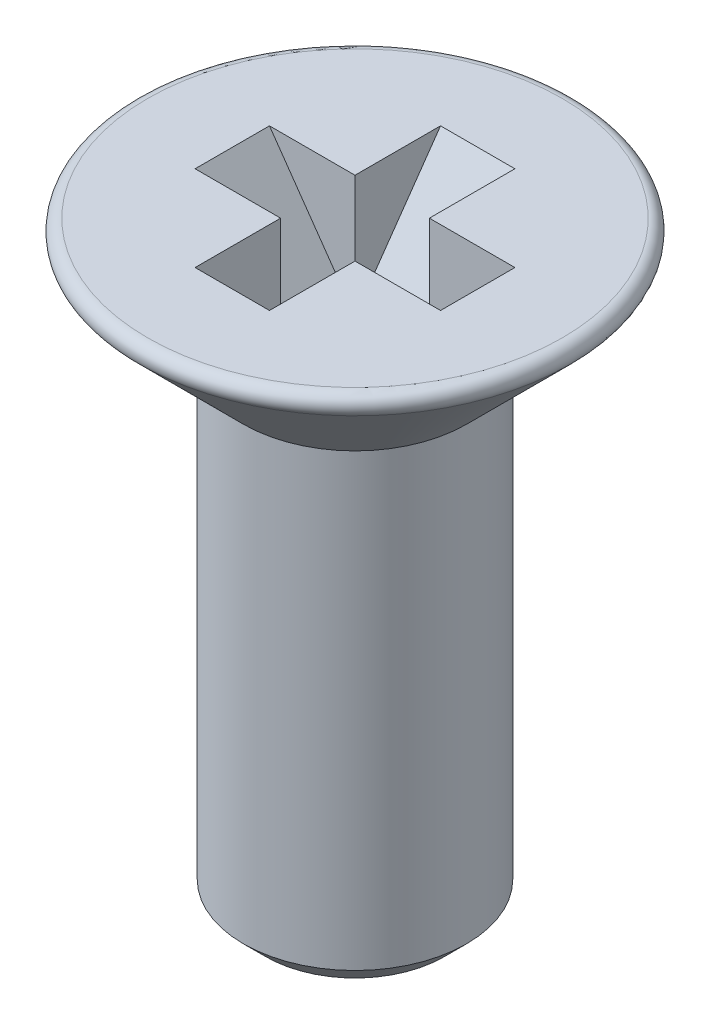
from build123d import *

# Parameters (mm, degrees)
ENL_V_MAT_EXTRU_2_DEPTH      = 0.5
R_P_TITION_CIRCULAIRE2_COUNT = 2
R_P_TITION_CIRCULAIRE2_ANGLE = 90


with BuildPart() as part:
    # Esquisse1 → Révolution1 (revolve)
    with BuildSketch(Plane.XY, mode=Mode.PRIVATE) as r_volution1_sk:
        with BuildLine():
            Line((0, 0), (-2.787867966, 0))
            ThreePointArc((-2.787867966, 0), (-2.926449896, -0.092597485), (-2.893933983, -0.256066017))
            Line((-2.893933983, -0.256066017), (-1.5, -1.65))
            Line((-1.5, -1.65), (-1.5, -7.7))
            Line((-1.5, -7.7), (-1.2, -8))
            Line((-1.2, -8), (0, -8))
            Line((0, -8), (0, 0))
        make_face()
    revolve(r_volution1_sk.sketch.rotate(Axis((0, -8, 0), (0, 1, 0)), 180), axis=Axis((0, -8, 0), (0, 1, 0)))  # turned: the seam where the file's is

    # Esquisse4 → Enlèv. mat.-Extru.2 (cut, symmetric)
    with BuildSketch(Plane.XY):
        Polygon((-1.65, 0), (1.65, 0), (0.54440915, -1.578947368), (-0.54440915, -1.578947368), align=None)
    enl_v_mat_extru_2 = extrude(amount=ENL_V_MAT_EXTRU_2_DEPTH, both=True, mode=Mode.SUBTRACT)

    # Répétition circulaire2: Enlèv. mat.-Extru.2 ×2 about axis
    r_p_tition_circulaire2_axis = Axis((0, 0, 0), (0, 1, 0))
    for i in range(1, R_P_TITION_CIRCULAIRE2_COUNT):
        add(enl_v_mat_extru_2.rotate(r_p_tition_circulaire2_axis, i * R_P_TITION_CIRCULAIRE2_ANGLE / (R_P_TITION_CIRCULAIRE2_COUNT - 1)), mode=Mode.SUBTRACT)


solid = part.part
